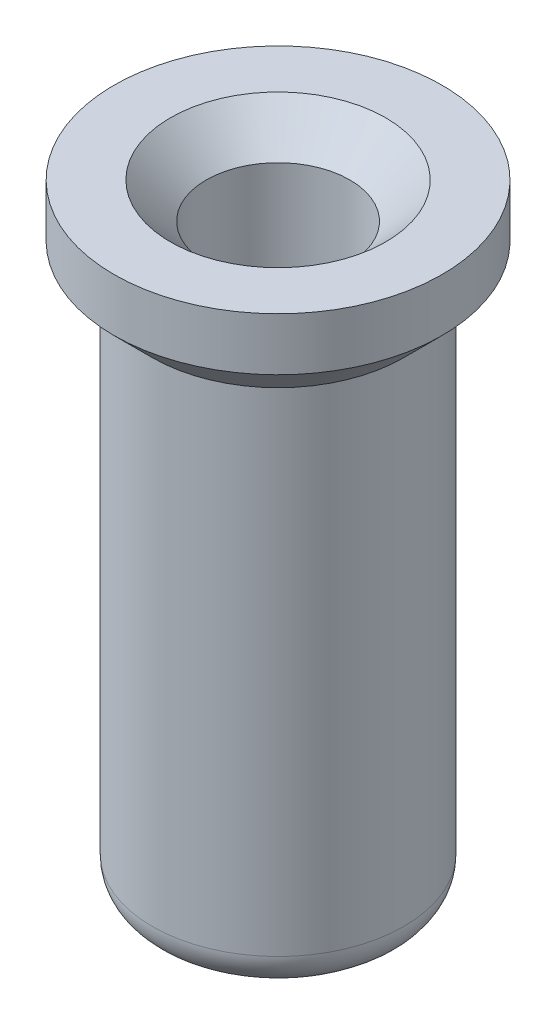
from build123d import *

# Parameters (mm, degrees)
F_1_0_1_DIAMETER_HOLE1_D     = 1
F_1_0_1_DIAMETER_HOLE1_DEPTH = 3.7338
F_1_0_1_DIAMETER_HOLE1_TIP   = 0.30043031
FILLET1_R                    = 0.25
CHAMFER1_SIZE                = 0.25


with BuildPart() as part:
    # Sketch1 → Revolve1 (revolve)
    with BuildSketch(Plane(origin=(0, 0, 0), x_dir=(0, 0, -1), z_dir=(1, 0, 0))):
        Polygon((0, 2.159), (1.143, 2.159), (1.143, 1.7907), (0.8763, 1.524), (0.8763, -2.159), (0, -2.159), align=None)
    revolve(axis=Axis((0, 2.159, 0), (0, -1, 0)))

    # Ø1.0 (1) Diameter Hole1
    with Locations(Plane.ZX.offset(2.159)):
        with Locations((0, 0)):
            Hole(F_1_0_1_DIAMETER_HOLE1_D / 2, depth=F_1_0_1_DIAMETER_HOLE1_DEPTH)
            with Locations((0, 0, -(F_1_0_1_DIAMETER_HOLE1_DEPTH + F_1_0_1_DIAMETER_HOLE1_TIP / 2))):  # 118° drill point
                Cone(0, F_1_0_1_DIAMETER_HOLE1_D / 2, F_1_0_1_DIAMETER_HOLE1_TIP, mode=Mode.SUBTRACT)

    # Fillet1
    fillet1_edges = [part.edges().sort_by_distance(p)[0] for p in [
        (0, -2.159, 0.8763),
    ]]
    fillet(fillet1_edges, radius=FILLET1_R)

    # Chamfer1
    chamfer1_edges = [part.edges().sort_by_distance(p)[0] for p in [
        (0, 2.159, 0.5),
    ]]
    chamfer(chamfer1_edges, length=CHAMFER1_SIZE)


solid = part.part
